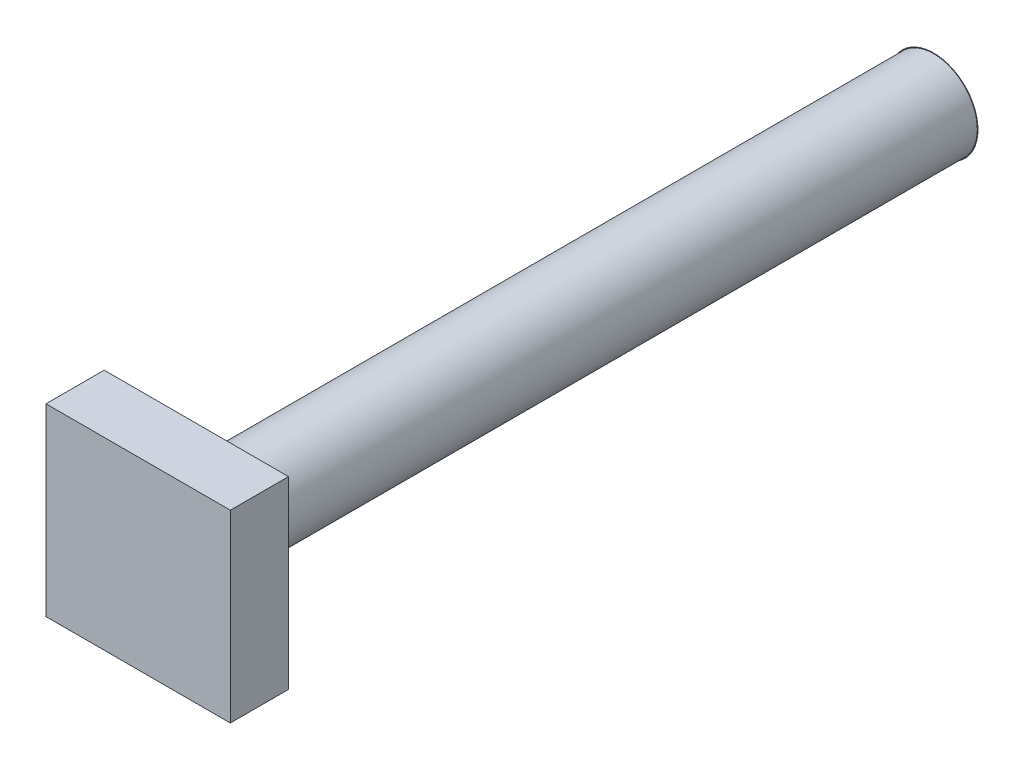
from build123d import *

# Parameters (mm, degrees)
SKETCH2_W           = 19
SKETCH2_H           = 19
BOSS_EXTRUDE1_DEPTH = 6
SKETCH4_R           = 4.5
BOSS_EXTRUDE2_DEPTH = 76


with BuildPart() as part:
    # Sketch2 → Boss-Extrude1 (new body)
    with BuildSketch(Plane.XY):
        Rectangle(SKETCH2_W, SKETCH2_H)
    extrude(amount=BOSS_EXTRUDE1_DEPTH)

    # Sketch4 → Boss-Extrude2 (add)
    with BuildSketch(Plane(origin=(0, 0, 0), x_dir=(-1, 0, 0), z_dir=(0, 0, -1))):
        with Locations(Location((0, 0, 0), (0, 0, 180))):  # turned: the seam where the file's is
            Circle(SKETCH4_R)
    extrude(amount=BOSS_EXTRUDE2_DEPTH)

    # Sketch6 → Revolve2 (revolve)
    with BuildSketch(Plane(origin=(0, 0, 0), x_dir=(0, 0, -1), z_dir=(1, 0, 0)), mode=Mode.PRIVATE) as revolve2_sk:
        with BuildLine():
            Line((76, 0), (76, -4.56928672))
            ThreePointArc((76, -4.56928672), (76.351816001, -2.296672068), (76.469498907, 0))
            Line((76.469498907, 0), (76, 0))
        make_face()
    revolve(revolve2_sk.sketch.rotate(Axis((0, 0, -76), (0, 0, -1)), 270), axis=Axis((0, 0, -76), (0, 0, -1)))  # turned: the seam where the file's is


solid = part.part
